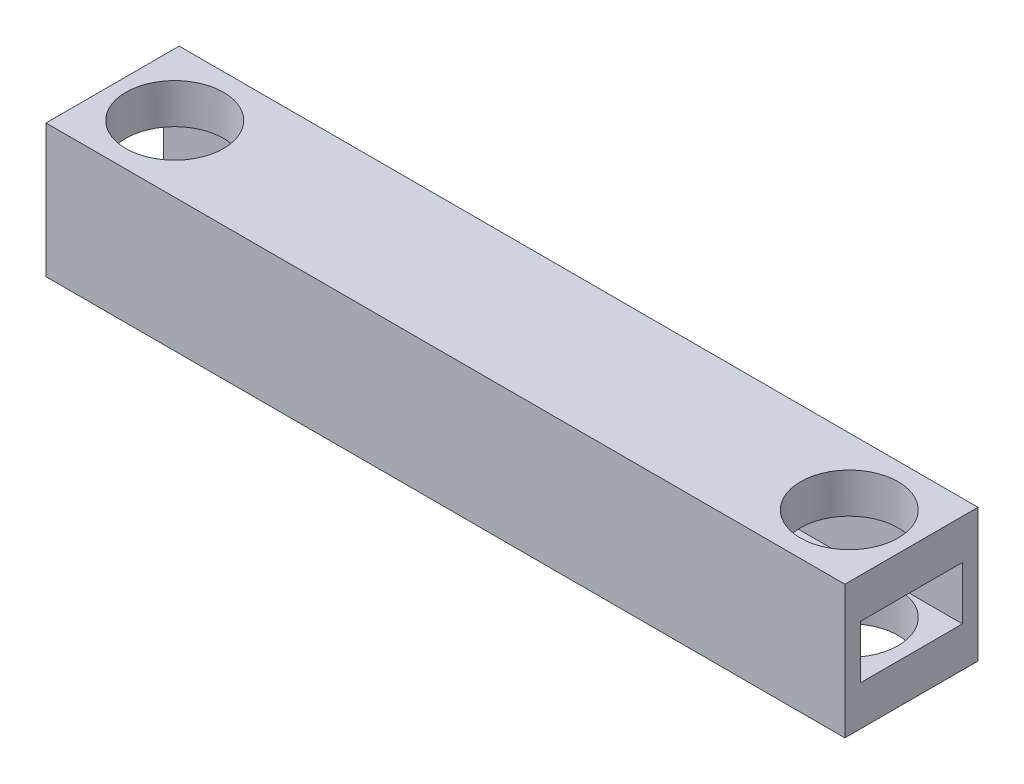
from build123d import *

# Parameters (mm, degrees)
SKETCH1_W               = 180
SKETCH1_H               = 30
BOSS_EXTRUDE1_DEPTH     = 30
SKETCH2_R               = 11
CUT_EXTRUDE1_DEPTH      = 1
CUT_EXTRUDE1_DEPTH_BACK = 31
SKETCH3_W               = 23
SKETCH3_H               = 12
CUT_EXTRUDE2_DEPTH      = 1
CUT_EXTRUDE2_DEPTH_BACK = 181
SKETCH6_R               = 11
CUT_EXTRUDE5_DEPTH      = 1
CUT_EXTRUDE5_DEPTH_BACK = 31


with BuildPart() as part:
    # Sketch1 → Boss-Extrude1 (new body)
    with BuildSketch(Plane.XY):
        with Locations((35.284090909, 4.517045455)):
            Rectangle(SKETCH1_W, SKETCH1_H)
    extrude(amount=BOSS_EXTRUDE1_DEPTH)

    # Sketch2 → Cut-Extrude1 (cut, two sides)
    with BuildSketch(Plane(origin=(0, 19.517045455, 0), x_dir=(1, 0, 0), z_dir=(0, 1, 0))) as cut_extrude1_sk:
        with Locations((-40.715909091, -15)):
            Circle(SKETCH2_R)
    extrude(amount=CUT_EXTRUDE1_DEPTH, mode=Mode.SUBTRACT)
    extrude(cut_extrude1_sk.sketch, amount=-CUT_EXTRUDE1_DEPTH_BACK, mode=Mode.SUBTRACT)

    # Sketch3 → Cut-Extrude2 (cut, two sides)
    with BuildSketch(Plane.ZY.offset(54.715909091)) as cut_extrude2_sk:
        with Locations((15, 4.517045455)):
            Rectangle(SKETCH3_W, SKETCH3_H)
    extrude(amount=CUT_EXTRUDE2_DEPTH, mode=Mode.SUBTRACT)
    extrude(cut_extrude2_sk.sketch, amount=-CUT_EXTRUDE2_DEPTH_BACK, mode=Mode.SUBTRACT)

    # Sketch6 → Cut-Extrude5 (cut, two sides)
    with BuildSketch(Plane(origin=(0, 19.517045455, 0), x_dir=(1, 0, 0), z_dir=(0, 1, 0))) as cut_extrude5_sk:
        with Locations((111.284090909, -15)):
            Circle(SKETCH6_R)
    extrude(amount=CUT_EXTRUDE5_DEPTH, mode=Mode.SUBTRACT)
    extrude(cut_extrude5_sk.sketch, amount=-CUT_EXTRUDE5_DEPTH_BACK, mode=Mode.SUBTRACT)


solid = part.part
